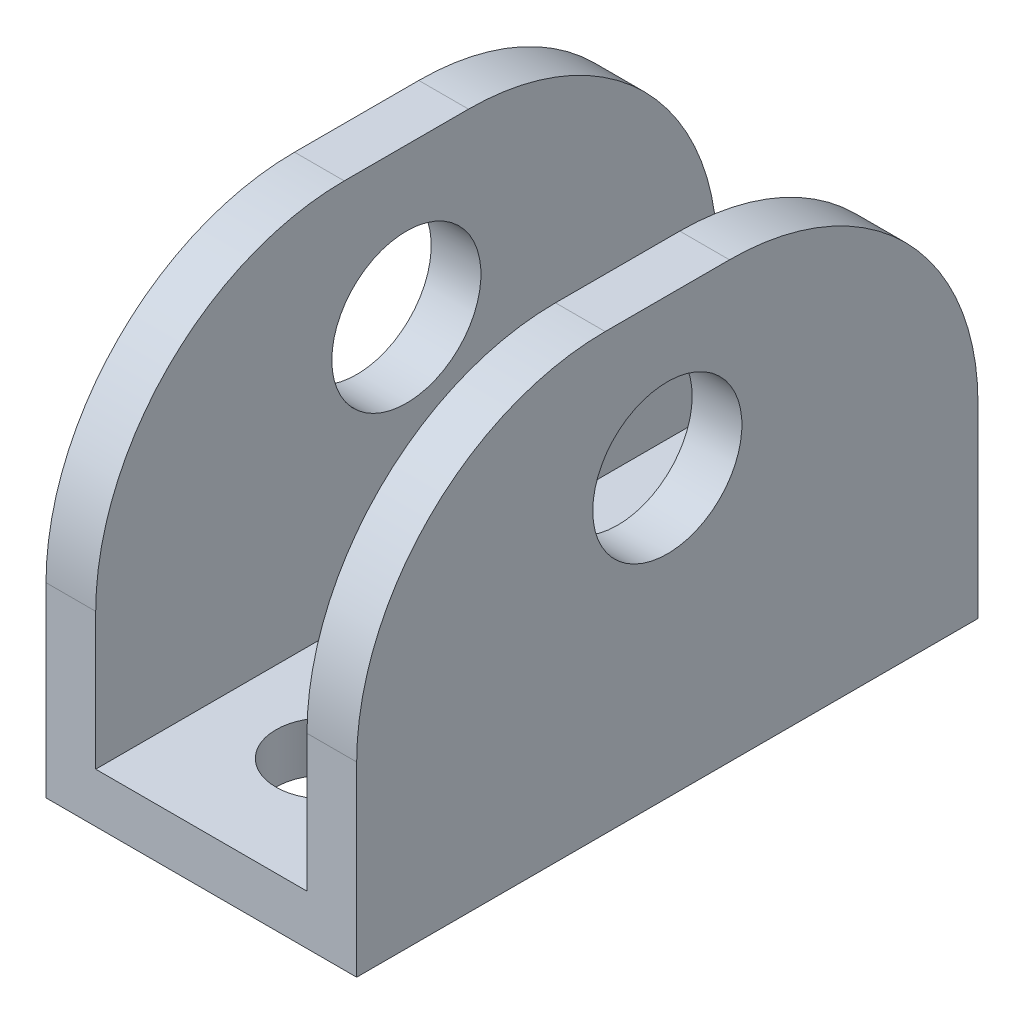
from build123d import *

# Parameters (mm, degrees)
SKETCH1_W           = 50
SKETCH1_H           = 35
BOSS_EXTRUDE1_DEPTH = 25
SKETCH2_W           = 17
SKETCH2_H           = 50
CUT_EXTRUDE1_DEPTH  = 31
SKETCH4_R           = 6
CUT_EXTRUDE2_DEPTH  = 26
SKETCH5_R           = 4
CUT_EXTRUDE3_DEPTH  = 4
FILLET1_R           = 20


with BuildPart() as part:
    # Sketch1 → Boss-Extrude1 (new body)
    with BuildSketch(Plane(origin=(0, 0, 0), x_dir=(0, 0, -1), z_dir=(1, 0, 0))):
        Rectangle(SKETCH1_W, SKETCH1_H)
    extrude(amount=BOSS_EXTRUDE1_DEPTH)

    # Sketch2 → Cut-Extrude1 (cut)
    with BuildSketch(Plane(origin=(0, 17.5, 0), x_dir=(1, 0, 0), z_dir=(0, 1, 0))):
        with Locations((12.5, 0)):
            Rectangle(SKETCH2_W, SKETCH2_H)
    extrude(amount=-CUT_EXTRUDE1_DEPTH, mode=Mode.SUBTRACT)

    # Sketch4 → Cut-Extrude2 (cut, through all)
    with BuildSketch(Plane.ZY):
        with Locations((0, 5.5)):
            Circle(SKETCH4_R)
    extrude(amount=-CUT_EXTRUDE2_DEPTH, mode=Mode.SUBTRACT)

    # Sketch5 → Cut-Extrude3 (cut)
    with BuildSketch(Plane.XZ.offset(17.5)):
        with Locations((12.5, 15)):
            Circle(SKETCH5_R)
        with Locations((12.5, -15)):
            Circle(SKETCH5_R)
    extrude(amount=-CUT_EXTRUDE3_DEPTH, mode=Mode.SUBTRACT)

    # Fillet1
    fillet1_edges = [part.edges().sort_by_distance(p)[0] for p in [
        (2, 17.5, 25),
        (2, 17.5, -25),
        (23, 17.5, 25),
        (23, 17.5, -25),
    ]]
    fillet(fillet1_edges, radius=FILLET1_R)


solid = part.part
